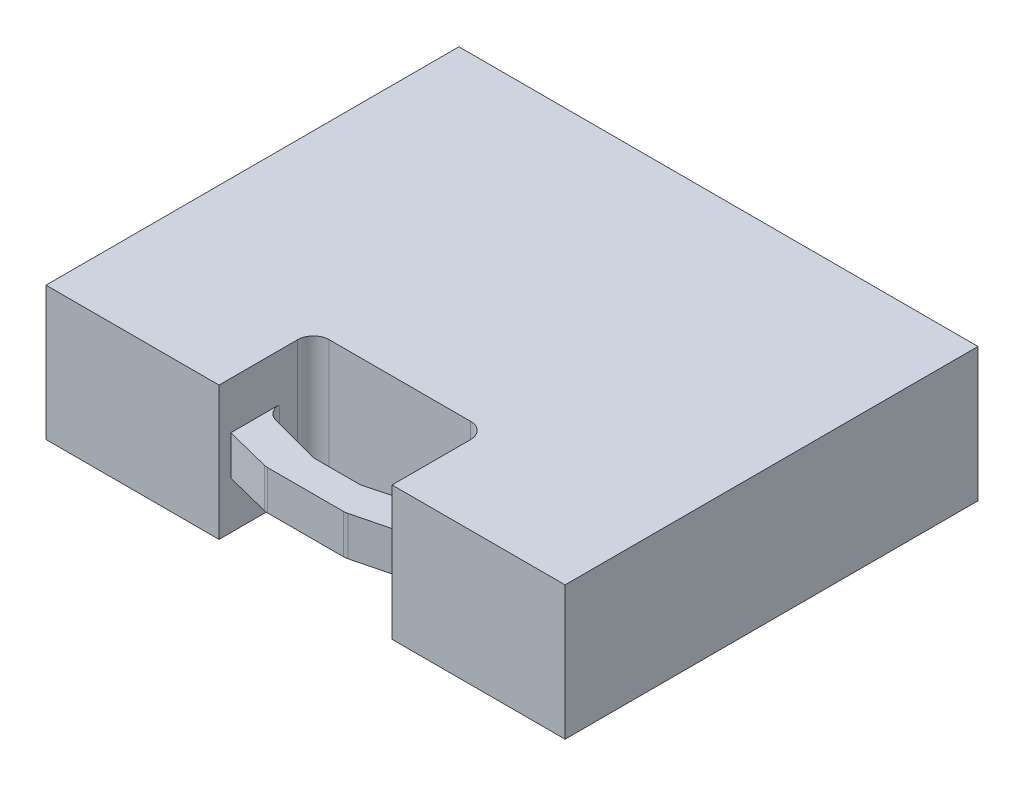
from build123d import *

# Parameters (mm, degrees)
SKETCH1_W           = 419.1
SKETCH1_H           = 333.375
BOSS_EXTRUDE1_DEPTH = 107.95
SKETCH2_W           = 139.7
SKETCH2_H           = 50.8
CUT_EXTRUDE1_DEPTH  = 108.95
CHAMFER1_SIZE       = 50.8
CHAMFER1_SIZE2      = 13.611818976
FILLET1_R           = 12.7
SKETCH3_W           = 139.7
SKETCH3_H           = 56.403006085
CUT_EXTRUDE2_DEPTH  = 38.1
SKETCH4_W           = 139.7
SKETCH4_H           = 56.128435861
CUT_EXTRUDE3_DEPTH  = 38.1


with BuildPart() as part:
    # Sketch1 → Boss-Extrude1 (new body)
    with BuildSketch(Plane(origin=(0, 0, 0), x_dir=(1, 0, 0), z_dir=(0, 1, 0))):
        Rectangle(SKETCH1_W, SKETCH1_H)
    extrude(amount=BOSS_EXTRUDE1_DEPTH)

    # Sketch2 → Cut-Extrude1 (cut, through all)
    with BuildSketch(Plane(origin=(0, 107.95, 0), x_dir=(1, 0, 0), z_dir=(0, 1, 0))):
        with Locations((0, -115.8875)):
            Rectangle(SKETCH2_W, SKETCH2_H)
        Polygon((-69.85, -166.6875), (-69.85, -157.1625), (-32.169017961, -166.6875), align=None)
        Polygon((32.169017961, -166.6875), (69.85, -166.6875), (69.85, -157.1625), align=None)
    extrude(amount=-CUT_EXTRUDE1_DEPTH, mode=Mode.SUBTRACT)

    # Chamfer1
    chamfer1_edges = [part.edges().sort_by_distance(p)[0] for p in [
        (69.85, 53.975, 141.2875),
        (-69.85, 53.975, 141.2875),
    ]]
    chamfer1_side = [part.faces().sort_by_distance(p)[0] for p in [
        (0, 53.975, 141.2875),
    ]]
    chamfer(chamfer1_edges, length=CHAMFER1_SIZE, length2=CHAMFER1_SIZE2, reference=chamfer1_side[0])

    # Fillet1
    fillet1_edges = [part.edges().sort_by_distance(p)[0] for p in [
        (69.85, 53.975, 90.4875),
        (-69.85, 53.975, 90.4875),
        (-32.169017961, 53.975, 166.6875),
        (32.169017961, 53.975, 166.6875),
        (69.85, 53.975, 127.675681024),
        (-19.05, 53.975, 141.2875),
        (19.05, 53.975, 141.2875),
        (-69.85, 53.975, 127.675681024),
    ]]
    fillet(fillet1_edges, radius=FILLET1_R)

    # Sketch3 → Cut-Extrude2 (cut)
    with BuildSketch(Plane(origin=(0, 107.95, 0), x_dir=(1, 0, 0), z_dir=(0, 1, 0))):
        with Locations((0, -138.485996957)):
            Rectangle(SKETCH3_W, SKETCH3_H)
    extrude(amount=-CUT_EXTRUDE2_DEPTH, mode=Mode.SUBTRACT)

    # Sketch4 → Cut-Extrude3 (cut)
    with BuildSketch(Plane.XZ):
        with Locations((0, 138.623282069)):
            Rectangle(SKETCH4_W, SKETCH4_H)
    extrude(amount=-CUT_EXTRUDE3_DEPTH, mode=Mode.SUBTRACT)


solid = part.part
